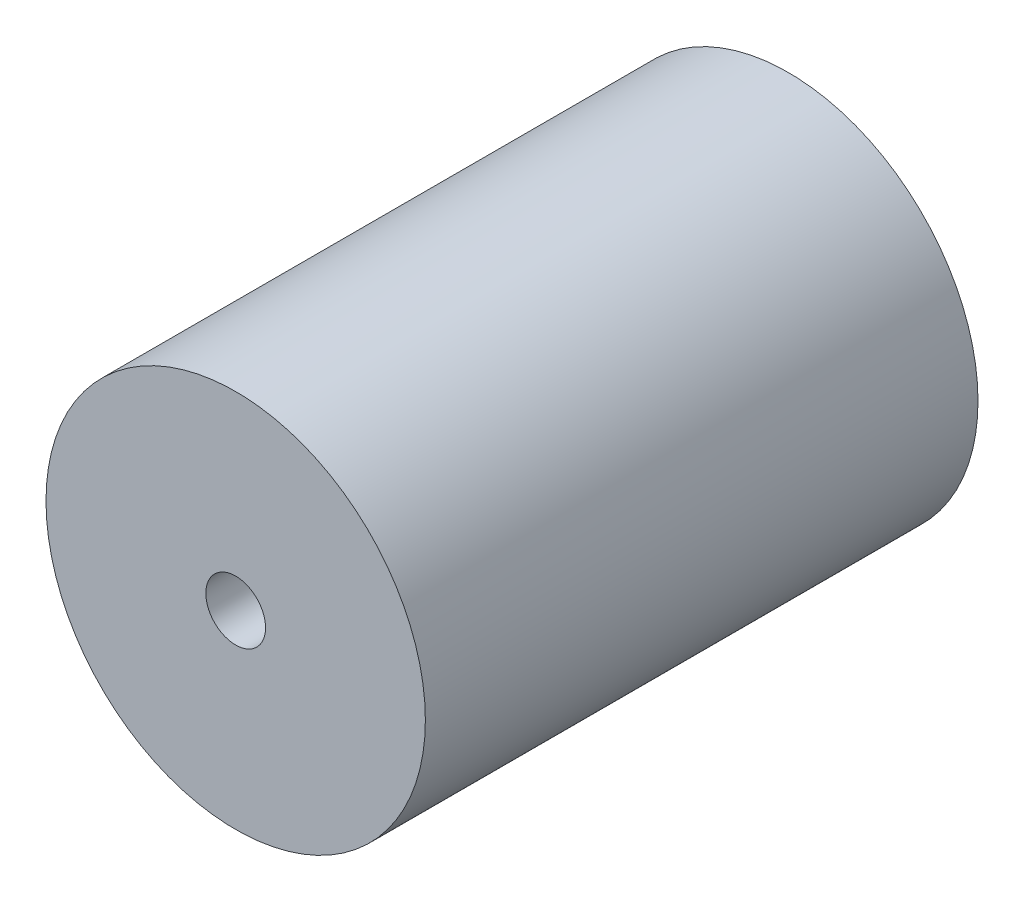
from build123d import *

# Parameters (mm, degrees)
SKETCH1_R           = 25.4
SKETCH1_R_2         = 4
BOSS_EXTRUDE1_DEPTH = 37


with BuildPart() as part:
    # Sketch1 → Boss-Extrude1 (new body, symmetric)
    with BuildSketch(Plane.XY):
        Circle(SKETCH1_R)
        Circle(SKETCH1_R_2, mode=Mode.SUBTRACT)
    extrude(amount=BOSS_EXTRUDE1_DEPTH, both=True)


solid = part.part
